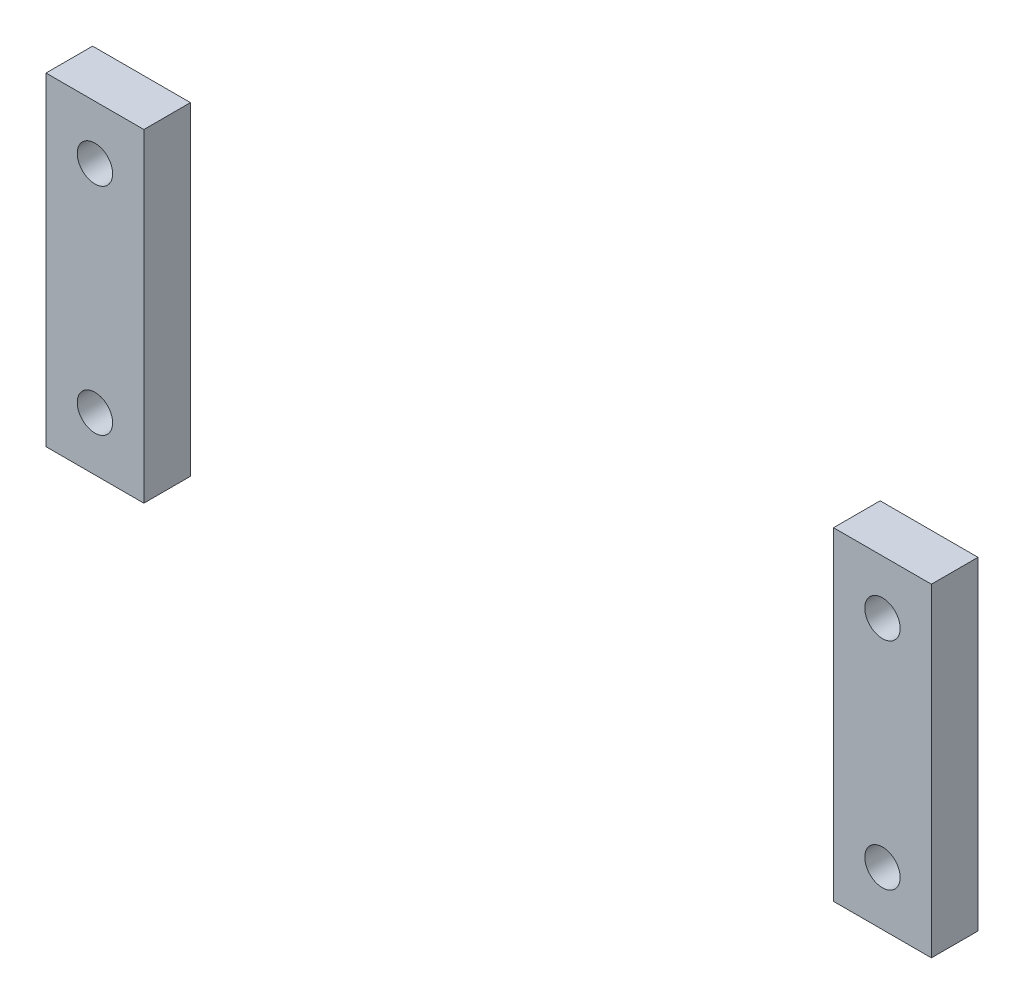
from build123d import *

# Parameters (mm, degrees)
SKETCH1_W                      = 10.5
SKETCH1_H                      = 34.725
BOSS_EXTRUDE1_DEPTH            = 5
BOSS_EXTRUDE1_2_DEPTH          = 5
SKETCH7_W                      = 1.89865
SKETCH7_H                      = 5
F_6_CLEARANCE_HOLE2_AT_2_COUNT = 2
F_6_CLEARANCE_HOLE2_AT_2_PITCH = 23.15
F_6_CLEARANCE_HOLE2_AT_3_COUNT = 2
F_6_CLEARANCE_HOLE2_AT_3_PITCH = 84.5
F_6_CLEARANCE_HOLE2_AT_4_COUNT = 2
F_6_CLEARANCE_HOLE2_AT_4_PITCH = 87.613768895


with BuildPart() as part:
    # Sketch1 → Boss-Extrude1 (new body)
    with BuildSketch(Plane.XY.offset(3)):
        with Locations((42.25, 0)):
            Rectangle(SKETCH1_W, SKETCH1_H)
    extrude(amount=BOSS_EXTRUDE1_DEPTH)

    # Sketch7 → #6 Clearance Hole2 (revolve, cut)
    with BuildSketch(Plane(origin=(42.25, 11.575, 8), x_dir=(0, -1, 0), z_dir=(1, 0, 0))):
        with Locations((0.949325, 2.5)):
            Rectangle(SKETCH7_W, SKETCH7_H)
    f_6_clearance_hole2 = revolve(axis=Axis((42.25, 11.575, 14.35), (0, 0, -1)), mode=Mode.SUBTRACT)

    # #6 Clearance Hole2 at 2: #6 Clearance Hole2 ×2
    with Locations(*[(0, -i * F_6_CLEARANCE_HOLE2_AT_2_PITCH, 0) for i in range(1, F_6_CLEARANCE_HOLE2_AT_2_COUNT)]):
        add(f_6_clearance_hole2, mode=Mode.SUBTRACT)


with BuildPart() as body_2:
    # Sketch1 → Boss-Extrude1 2 (new body)
    with BuildSketch(Plane.XY.offset(3)):
        with Locations((-42.25, 0)):
            Rectangle(SKETCH1_W, SKETCH1_H)
    extrude(amount=BOSS_EXTRUDE1_2_DEPTH)

    # #6 Clearance Hole2 at 3: #6 Clearance Hole2 ×2
    with Locations(*[(-i * F_6_CLEARANCE_HOLE2_AT_3_PITCH, 0, 0) for i in range(1, F_6_CLEARANCE_HOLE2_AT_3_COUNT)]):
        add(f_6_clearance_hole2, mode=Mode.SUBTRACT)

    # #6 Clearance Hole2 at 4: #6 Clearance Hole2 ×2
    with Locations(*[Vector(-0.964460279, -0.264227875, 0) * (i * F_6_CLEARANCE_HOLE2_AT_4_PITCH) for i in range(1, F_6_CLEARANCE_HOLE2_AT_4_COUNT)]):
        add(f_6_clearance_hole2, mode=Mode.SUBTRACT)


solid = Compound([part.part, body_2.part])
